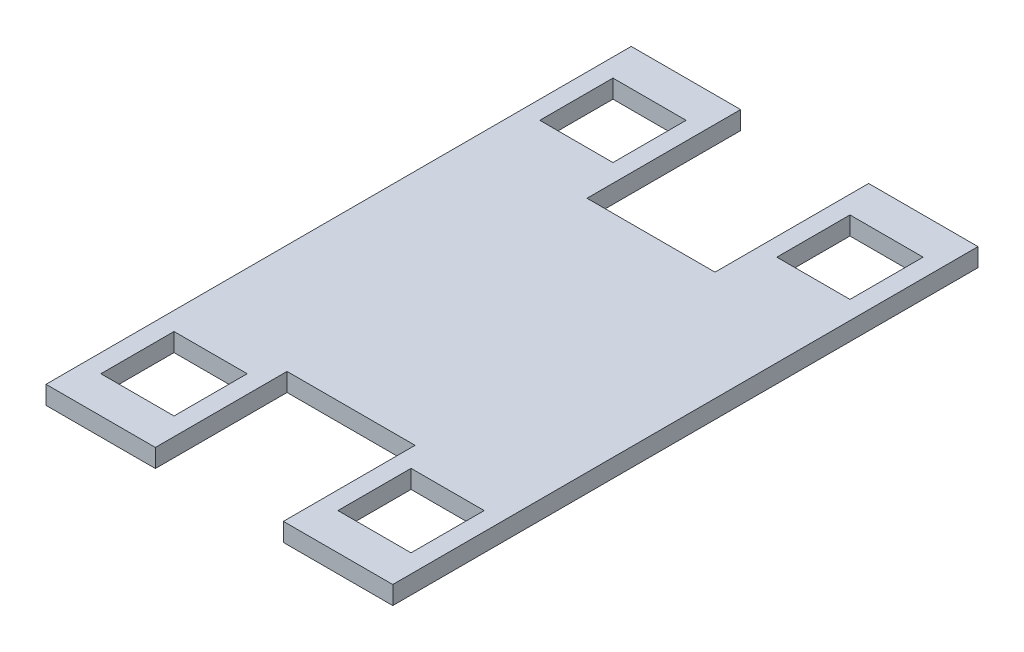
from build123d import *

# Parameters (mm, degrees)
SKETCH1_W               = 120.396
SKETCH1_H               = 203.2
BOSS_EXTRUDE1_DEPTH     = 6.35
CUT_EXTRUDE1_START      = -7.35
SKETCH2_W               = 25.4
SKETCH2_H               = 25.4
CUT_EXTRUDE1_DEPTH      = 8.35
MIRROR2_START           = -7.35
MIRROR2_COPY_1_SKETCH_W = 25.4
MIRROR2_COPY_1_SKETCH_H = 25.4
MIRROR2_COPY_1_DEPTH    = 8.35
SKETCH3_W               = 44.45
SKETCH3_H               = 45.72
SKETCH3_H_2             = 53.34
CUT_EXTRUDE2_DEPTH      = 7.35


with BuildPart() as part:
    # Sketch1 → Boss-Extrude1 (new body)
    with BuildSketch(Plane(origin=(0, 0, 0), x_dir=(1, 0, 0), z_dir=(0, 1, 0))):
        Rectangle(SKETCH1_W, SKETCH1_H)
    extrude(amount=BOSS_EXTRUDE1_DEPTH)

    # Sketch2 → Cut-Extrude1 (cut)
    with BuildSketch(Plane(origin=(0, 6.35, 0), x_dir=(1, 0, 0), z_dir=(0, 1, 0)).offset(CUT_EXTRUDE1_START)):
        with Locations((-41.148, 76.2)):
            Rectangle(SKETCH2_W, SKETCH2_H)
    cut_extrude1 = extrude(amount=CUT_EXTRUDE1_DEPTH, mode=Mode.SUBTRACT)

    # Mirror1: Cut-Extrude1 across plane
    add(cut_extrude1.mirror(Plane.XY), mode=Mode.SUBTRACT)

    # Mirror2: Cut-Extrude1 across plane
    add(cut_extrude1.mirror(Plane(origin=(0, 0, 0), x_dir=(0, 0, 1), z_dir=(1, 0, 0))), mode=Mode.SUBTRACT)

    # Mirror2 copy 1 sketch → Mirror2 copy 1 (cut)
    with BuildSketch(Plane(origin=(0, 6.35, 0), x_dir=(-1, 0, 0), z_dir=(0, 1, 0)).offset(MIRROR2_START)):
        with Locations((-41.148, 76.2)):
            Rectangle(MIRROR2_COPY_1_SKETCH_W, MIRROR2_COPY_1_SKETCH_H)
    extrude(amount=MIRROR2_COPY_1_DEPTH, mode=Mode.SUBTRACT)

    # Sketch3 → Cut-Extrude2 (cut, through all)
    with BuildSketch(Plane(origin=(0, 6.35, 0), x_dir=(1, 0, 0), z_dir=(0, 1, 0))):
        with Locations((0, -78.74)):
            Rectangle(SKETCH3_W, SKETCH3_H)
        with Locations((0, 74.93)):
            Rectangle(SKETCH3_W, SKETCH3_H_2)
    extrude(amount=-CUT_EXTRUDE2_DEPTH, mode=Mode.SUBTRACT)


solid = part.part
